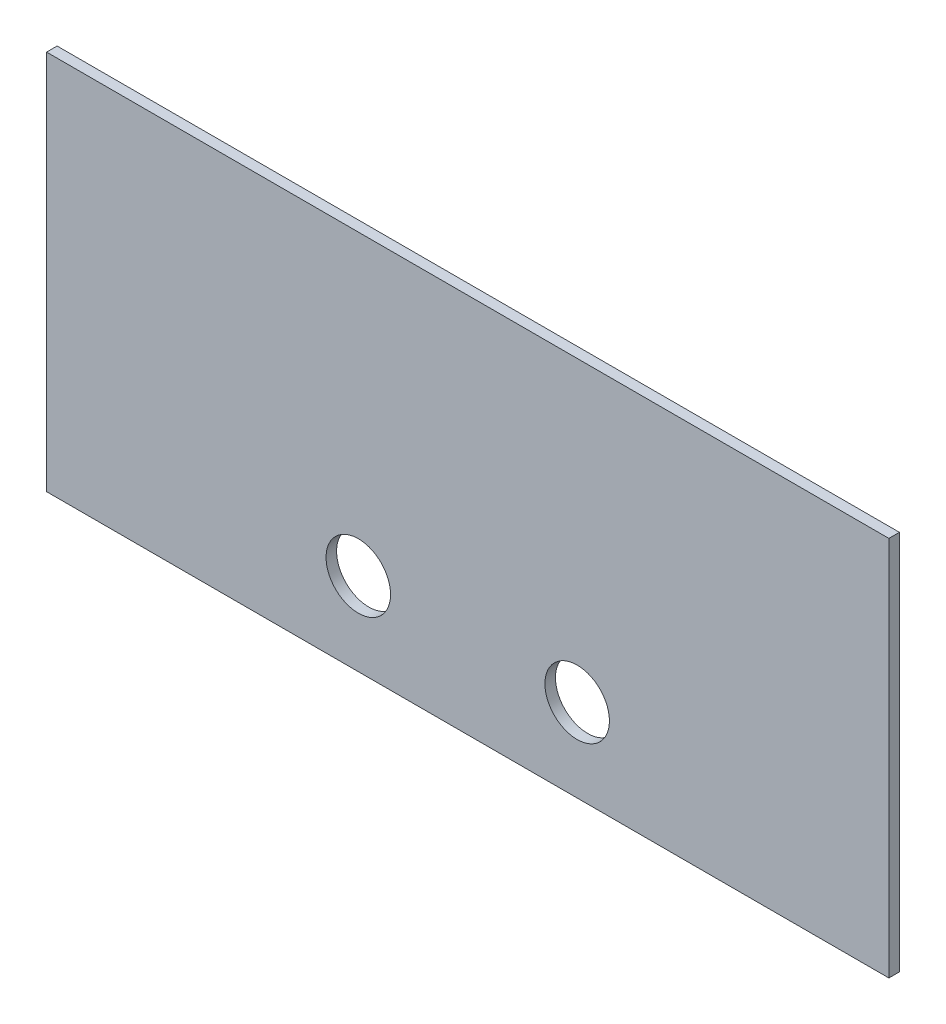
from build123d import *

# Parameters (mm, degrees)
SKETCH1_W           = 127
SKETCH1_H           = 57.404
SKETCH1_R           = 4.864
BOSS_EXTRUDE1_DEPTH = 1.5875


with BuildPart() as part:
    # Sketch1 → Boss-Extrude1 (new body)
    with BuildSketch(Plane.XY):
        with Locations((63.5, 28.702)):
            Rectangle(SKETCH1_W, SKETCH1_H)
        with Locations((80, 12.500102)):
            Circle(SKETCH1_R, mode=Mode.SUBTRACT)
        with Locations((47, 12.500102)):
            Circle(SKETCH1_R, mode=Mode.SUBTRACT)
    extrude(amount=BOSS_EXTRUDE1_DEPTH)


solid = part.part
